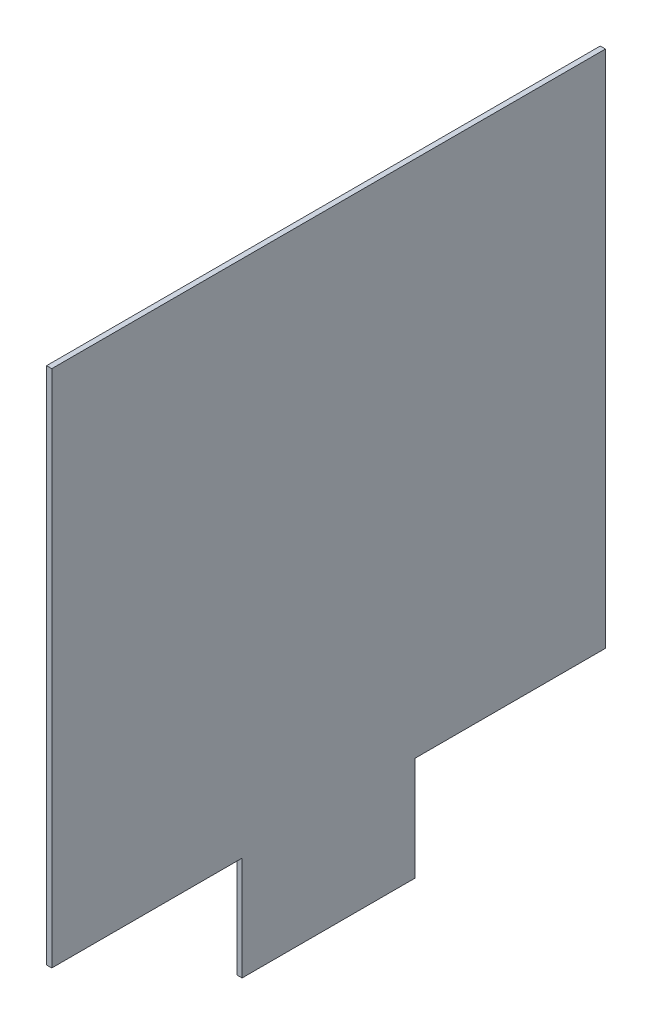
from build123d import *

# Parameters (mm, degrees)
BOSS_EXTRUDE1_DEPTH = 3


with BuildPart() as part:
    # Sketch1 → Boss-Extrude1 (new body)
    with BuildSketch(Plane(origin=(0, 0, 0), x_dir=(0, 0, -1), z_dir=(1, 0, 0))):
        Polygon((-151.274571576, -55.704155978), (-41.274571576, -55.704155978), (-41.274571576, -115.704155978), (58.725428424, -115.704155978), (58.725428424, -55.704155978), (168.725428424, -55.704155978), (168.725428424, 244.295844022), (-151.274571576, 244.295844022), align=None)
    extrude(amount=BOSS_EXTRUDE1_DEPTH)


solid = part.part
